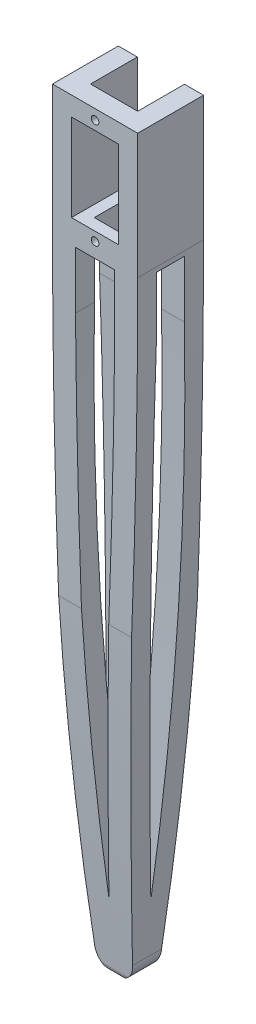
from build123d import *

# Parameters (mm, degrees)
BOSS_EXTRUDE2_DEPTH      = 5
SKETCH4_W                = 12.4
SKETCH4_H                = 22.9
CUT_EXTRUDE1_DEPTH       = 5
SKETCH5_R                = 1
CUT_EXTRUDE2_DEPTH       = 5
CUT_EXTRUDE3_DEPTH       = 5
SKETCH6_W                = 5
SKETCH6_H                = 22.9
BOSS_EXTRUDE3_DEPTH      = 12.3
SKETCH7_R                = 1
CUT_EXTRUDE4_DEPTH       = 5
BOSS_EXTRUDE4_DEPTH      = 12.3
CUT_EXTRUDE5_DEPTH       = 121
CUT_EXTRUDE7_DEPTH       = 185.302285774
CUT_EXTRUDE8_DEPTH       = 121
CUT_EXTRUDE12_DEPTH      = 60.5
CUT_EXTRUDE13_REACH      = 174.902
SKETCH16_W               = 6.4
SKETCH16_H               = 11.3
CUT_EXTRUDE14_DEPTH      = 185.703363647
SKETCH23_W               = 7.3
SKETCH23_H               = 15
CUT_EXTRUDE15_DEPTH      = 185.687725676
CUT_EXTRUDE15_DEPTH_BACK = 185.687725676
SKETCH24_W               = 5
SKETCH24_H               = 12.3
BOSS_EXTRUDE5_DEPTH      = 5
BOSS_EXTRUDE6_REACH      = 187.32
SKETCH25_W               = 17.3
SKETCH25_H               = 5
BOSS_EXTRUDE7_REACH      = 187.32
SKETCH26_W               = 5
SKETCH26_H               = 5


with BuildPart() as part:
    # Sketch1 → Boss-Extrude2 (new body)
    with BuildSketch(Plane.XY):
        with BuildLine():
            Line((-6.2, 16.45), (6.2, 16.45))
            ThreePointArc((6.2, 16.45), (9.735533906, 14.985533906), (11.2, 11.45))
            Line((11.2, 11.45), (11.2, -16.45))
            ThreePointArc((11.2, -16.45), (9.649433537, -97.559262726), (5, -178.55))
            ThreePointArc((5, -178.55), (0, -183.55), (-5, -178.55))
            ThreePointArc((-5, -178.55), (-9.649433537, -97.559262726), (-11.2, -16.45))
            Line((-11.2, -16.45), (-11.2, 11.45))
            ThreePointArc((-11.2, 11.45), (-9.735533906, 14.985533906), (-6.2, 16.45))
        make_face()
    extrude(amount=BOSS_EXTRUDE2_DEPTH)

    # Sketch4 → Cut-Extrude1 (cut)
    with BuildSketch(Plane.XY.offset(5)):
        Rectangle(SKETCH4_W, SKETCH4_H)
    extrude(amount=-CUT_EXTRUDE1_DEPTH, mode=Mode.SUBTRACT)

    # Sketch5 → Cut-Extrude2 (cut)
    with BuildSketch(Plane.XY.offset(5)):
        with Locations((0, 13.8)):
            Circle(SKETCH5_R)
        with Locations((0, -13.8)):
            Circle(SKETCH5_R)
    extrude(amount=-CUT_EXTRUDE2_DEPTH, mode=Mode.SUBTRACT)

    # 3DSketch1 → Cut-Extrude3 (cut)
    with BuildSketch(Plane(origin=(-5.160423987, -32.686439405, 5), x_dir=(0.03897452460138957, -0.9992402045715013, 0), z_dir=(0, 0, 1))):
        with BuildLine():
            Line((0, 0), (0.402250143, 10.313006243))
            add(Edge.make_bspline(
                [(132.405052787, 0), (132.33638536, 0.007627552), (132.26771744, 0.015250757), (132.19904902, 0.022869576), (126.769998736, 0.624873123), (121.337777255, 1.198987474), (115.971798773, 1.743277878), (102.55225111, 3.059162741), (89.125108856, 4.291856269), (81.065896409, 4.997231834), (64.94123124, 6.330918517), (48.803313346, 7.493309622), (40.731510594, 8.035951572), (27.824174172, 8.848610973), (14.911969374, 9.58457196), (10.076236862, 9.846020434), (5.23968635, 10.089957993), (0.402250143, 10.313006243)],
                knots=[0, 0, 0, 0, 0, 0, 0.002323761, 0.002323761, 0.002323761, 0.183719441, 0.183719441, 0.183719441, 0.455812961, 0.455812961, 0.455812961, 0.72790648, 0.72790648, 0.72790648, 0.890780205, 0.890780205, 0.890780205, 0.890780205, 0.890780205, 0.890780205], degree=5))
            add(Edge.make_bspline(
                [(0, 0), (4.840113133, -0.15441643), (9.680970327, -0.287938029), (14.522375928, -0.403938196), (27.452676969, -0.675942436), (40.384098451, -0.871102077), (48.473645133, -0.958819983), (64.653074032, -1.056939836), (80.832632652, -0.983252259), (88.922302572, -0.907750283), (102.404667084, -0.724639456), (115.885939838, -0.457998492), (121.278011015, -0.333316775), (126.738446926, -0.184061374), (132.197893558, -0.0067545), (132.266946789, -0.004507398), (132.335999865, -0.002255886), (132.405052787, 0)],
                knots=[0.109219795, 0.109219795, 0.109219795, 0.109219795, 0.109219795, 0.109219795, 0.27209352, 0.27209352, 0.27209352, 0.544187039, 0.544187039, 0.544187039, 0.816280559, 0.816280559, 0.816280559, 0.997676239, 0.997676239, 0.997676239, 1, 1, 1, 1, 1, 1], degree=5))
        make_face()
    extrude(amount=-CUT_EXTRUDE3_DEPTH, mode=Mode.SUBTRACT)

    # Sketch6 → Boss-Extrude3 (add)
    with BuildSketch(Plane(origin=(0, 0, 0), x_dir=(-1, 0, 0), z_dir=(0, 0, -1))):
        with Locations((-8.7, 0)):
            Rectangle(SKETCH6_W, SKETCH6_H)
        with Locations((8.7, 0)):
            Rectangle(SKETCH6_W, SKETCH6_H)
    extrude(amount=BOSS_EXTRUDE3_DEPTH)

    # Sketch7 → Cut-Extrude4 (cut)
    with BuildSketch(Plane(origin=(0, 0, -12.3), x_dir=(-1, 0, 0), z_dir=(0, 0, -1))):
        with Locations((-8.665838134, 0)):
            Circle(SKETCH7_R)
        with Locations((8.880503913, 0)):
            Circle(SKETCH7_R)
        with Locations((8.880503913, 6)):
            Circle(SKETCH7_R)
    extrude(amount=-CUT_EXTRUDE4_DEPTH, mode=Mode.SUBTRACT)

    # Sketch8 → Boss-Extrude4 (add)
    with BuildSketch(Plane(origin=(0, 0, 0), x_dir=(-1, 0, 0), z_dir=(0, 0, -1))):
        with BuildLine():
            Line((11.2, -16.45), (11.2, -11.45))
            Line((11.2, -11.45), (6.2, -11.45))
            Line((6.2, -11.45), (-6.2, -11.45))
            Line((-6.2, -11.45), (-11.2, -11.45))
            Line((-11.2, -11.45), (-11.2, -16.45))
            ThreePointArc((-11.2, -16.45), (-9.649433537, -97.559262726), (-5, -178.55))
            ThreePointArc((-5, -178.55), (0, -183.55), (5, -178.55))
            ThreePointArc((5, -178.55), (9.649433537, -97.559262726), (11.2, -16.45))
        make_face()
    extrude(amount=BOSS_EXTRUDE4_DEPTH)

    # Sketch10 → Cut-Extrude5 (cut)
    with BuildSketch(Plane.XY):
        with BuildLine():
            Line((5.16042399, -32.686439405), (-5.160423987, -32.686439405))
            add(Edge.make_bspline(
                [(-5.160423987, -32.686439405), (-5.126081984, -37.528893349), (-5.070832025, -42.371276423), (-4.998052574, -47.213524597), (-4.765897811, -60.144602491), (-4.456913166, -73.073804992), (-4.229278188, -81.160624037), (-3.69673794, -97.331584054), (-2.992515745, -113.495977582), (-2.601780096, -121.576558353), (-1.893339649, -135.041542369), (-1.10147508, -148.502179909), (-0.766734685, -153.885294805), (-0.404774794, -159.335764743), (-0.0148233, -164.784152861), (-0.009886589, -164.853066046), (-0.004945476, -164.921978904), (1e-09, -164.990891438)],
                knots=[0.109219795, 0.109219795, 0.109219795, 0.109219795, 0.109219795, 0.109219795, 0.27209352, 0.27209352, 0.27209352, 0.544187039, 0.544187039, 0.544187039, 0.816280559, 0.816280559, 0.816280559, 0.997676239, 0.997676239, 0.997676239, 1, 1, 1, 1, 1, 1], degree=5))
            add(Edge.make_bspline(
                [(1e-09, -164.990891438), (0.004945477, -164.921978904), (0.00988659, -164.853066046), (0.014823301, -164.784152861), (0.404774795, -159.335764743), (0.766734686, -153.885294805), (1.101475081, -148.502179909), (1.89333965, -135.041542369), (2.601780097, -121.576558353), (2.992515747, -113.495977582), (3.696737942, -97.331584054), (4.22927819, -81.160624037), (4.456913168, -73.073804992), (4.765897813, -60.144602491), (4.998052577, -47.213524597), (5.070832028, -42.371276423), (5.126081987, -37.528893349), (5.16042399, -32.686439405)],
                knots=[0, 0, 0, 0, 0, 0, 0.002323761, 0.002323761, 0.002323761, 0.183719441, 0.183719441, 0.183719441, 0.455812961, 0.455812961, 0.455812961, 0.72790648, 0.72790648, 0.72790648, 0.890780205, 0.890780205, 0.890780205, 0.890780205, 0.890780205, 0.890780205], degree=5))
        make_face()
    extrude(amount=-CUT_EXTRUDE5_DEPTH, mode=Mode.SUBTRACT)

    # Sketch12 → Cut-Extrude7 (cut, through all)
    with BuildSketch(Plane(origin=(0, 0, 0), x_dir=(0, 0, -1), z_dir=(1, 0, 0))):
        with BuildLine():
            Line((0, -32.686439405), (7.3, -32.686439405))
            ThreePointArc((7.3, -32.686439405), (7.305216991, -98.889157238), (3.65, -164.99089144))
            ThreePointArc((3.65, -164.99089144), (-0.005216991, -98.889157238), (0, -32.686439405))
        make_face()
    extrude(amount=-CUT_EXTRUDE7_DEPTH, mode=Mode.SUBTRACT)

    # Sketch14 → Cut-Extrude8 (cut)
    with BuildSketch(Plane(origin=(0, 0, 0), x_dir=(0, 0, -1), z_dir=(1, 0, 0))):
        with BuildLine():
            Line((7.3, -32.686439405), (0, -32.686439405))
            ThreePointArc((0, -32.686439405), (-0.005216991, -98.889157238), (3.65, -164.99089144))
            ThreePointArc((3.65, -164.99089144), (7.305216991, -98.889157238), (7.3, -32.686439405))
        make_face()
    extrude(amount=CUT_EXTRUDE8_DEPTH, mode=Mode.SUBTRACT)

    # Sketch15 → Cut-Extrude12 (cut, symmetric)
    with BuildSketch(Plane(origin=(0, 0, 0), x_dir=(0, 0, -1), z_dir=(1, 0, 0))):
        with BuildLine():
            Line((12.301916168, -32.686439405), (24.156676666, -32.686439405))
            Line((24.156676666, -32.686439405), (24.156676666, -183.55))
            Line((24.156676666, -183.55), (5.626116445, -183.55))
            ThreePointArc((5.626116445, -183.55), (6.634148123, -183.160797973), (7.119075837, -182.195162848))
            ThreePointArc((7.119075837, -182.195162848), (12.038912499, -107.52151756), (12.301916168, -32.686439405))
        make_face()
        with BuildLine():
            Line((-5.001916168, -32.686439405), (-15.644111431, -32.686439405))
            Line((-15.644111431, -32.686439405), (-15.644111431, -183.55))
            Line((-15.644111431, -183.55), (1.673883555, -183.55))
            ThreePointArc((1.673883555, -183.55), (0.665851877, -183.160797973), (0.180924163, -182.195162848))
            ThreePointArc((0.180924163, -182.195162848), (-4.738912499, -107.52151756), (-5.001916168, -32.686439405))
        make_face()
    extrude(amount=CUT_EXTRUDE12_DEPTH, both=True, mode=Mode.SUBTRACT)

    # Sketch16 → Cut-Extrude13 (cut, up to next)
    with BuildSketch(Plane(origin=(0, -11.45, 0), x_dir=(1, 0, 0), z_dir=(0, 1, 0)), mode=Mode.PRIVATE) as cut_extrude13_sk1:
        with Locations((0, 3.65)):
            Rectangle(SKETCH16_W, SKETCH16_H)
    cut_extrude13_tool1 = extrude(cut_extrude13_sk1.sketch, amount=-CUT_EXTRUDE13_REACH, mode=Mode.PRIVATE) & part.part
    add(cut_extrude13_tool1.solids().sort_by_distance((0, -11.45, -3.65))[0], mode=Mode.SUBTRACT)

    # Sketch21 → Cut-Extrude14 (cut, through all)
    with BuildSketch(Plane.XY.offset(5)):
        Polygon((-5.160423987, -32.686439405), (5.16042399, -32.686439405), (5.160423987, -17.686439405), (-5.160423987, -17.686439405), align=None)
    extrude(amount=-CUT_EXTRUDE14_DEPTH, mode=Mode.SUBTRACT)

    # Sketch23 → Cut-Extrude15 (cut, two sides)
    with BuildSketch(Plane(origin=(-5.160423987, 0, 0), x_dir=(0, 0, -1), z_dir=(1, 0, 0))) as cut_extrude15_sk:
        with Locations((3.65, -25.186439405)):
            Rectangle(SKETCH23_W, SKETCH23_H)
    extrude(amount=CUT_EXTRUDE15_DEPTH, mode=Mode.SUBTRACT)
    extrude(cut_extrude15_sk.sketch, amount=-CUT_EXTRUDE15_DEPTH_BACK, mode=Mode.SUBTRACT)

    # Sketch24 → Boss-Extrude5 (add)
    with BuildSketch(Plane(origin=(0, 11.45, 0), x_dir=(1, 0, 0), z_dir=(0, 1, 0))):
        with Locations((8.7, 6.15)):
            Rectangle(SKETCH24_W, SKETCH24_H)
        with Locations((-8.7, 6.15)):
            Rectangle(SKETCH24_W, SKETCH24_H)
    extrude(amount=BOSS_EXTRUDE5_DEPTH)

    # Sketch25 → Boss-Extrude6 (add, up to next)
    with BuildSketch(Plane(origin=(11.2, 0, 0), x_dir=(0, 0, -1), z_dir=(1, 0, 0)), mode=Mode.PRIVATE) as boss_extrude6_sk1:
        with Locations((3.65, 13.95)):
            Rectangle(SKETCH25_W, SKETCH25_H)
    boss_extrude6_tool1 = extrude(boss_extrude6_sk1.sketch, amount=-BOSS_EXTRUDE6_REACH, mode=Mode.PRIVATE) - part.part
    add(boss_extrude6_tool1.solids().sort_by_distance((11.2, 13.95, -3.65))[0])

    # Sketch26 → Boss-Extrude7 (add, up to next)
    with BuildSketch(Plane.ZY.offset(11.2), mode=Mode.PRIVATE) as boss_extrude7_sk1:
        with Locations((2.5, 13.95)):
            Rectangle(SKETCH26_W, SKETCH26_H)
    boss_extrude7_tool1 = extrude(boss_extrude7_sk1.sketch, amount=-BOSS_EXTRUDE7_REACH, mode=Mode.PRIVATE) - part.part
    add(boss_extrude7_tool1.solids().sort_by_distance((-11.2, 13.95, 2.5))[0])


solid = part.part
